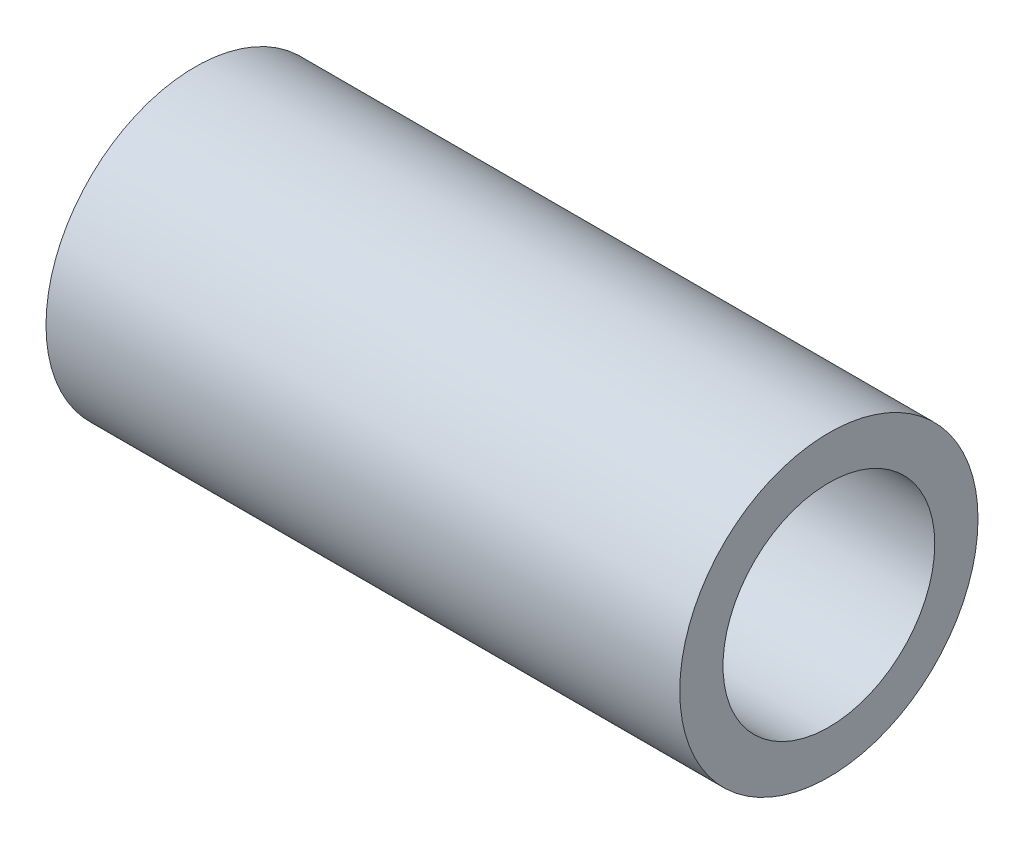
from build123d import *

# Parameters (mm, degrees)
SKETCH2_R          = 12.7
SKETCH2_R_2        = 11.2141
EXTRUDE1_DEPTH     = 28.575
SKETCH3_R          = 12.7
SKETCH3_R_2        = 9.017
EXTRUDE2_DEPTH     = 25.4
SKETCH4_R          = 11.2141
SKETCH4_R_2        = 9.017
CUT_EXTRUDE3_DEPTH = 3.175


with BuildPart() as part:
    # Sketch2 → Extrude1 (new body)
    with BuildSketch(Plane(origin=(0, 0, 0), x_dir=(0, 0, -1), z_dir=(1, 0, 0))):
        Circle(SKETCH2_R)
        Circle(SKETCH2_R_2, mode=Mode.SUBTRACT)
    extrude(amount=EXTRUDE1_DEPTH)

    # Sketch3 → Extrude2 (add)
    with BuildSketch(Plane(origin=(28.575, 0, 0), x_dir=(0, 0, -1), z_dir=(1, 0, 0))):
        Circle(SKETCH3_R)
        Circle(SKETCH3_R_2, mode=Mode.SUBTRACT)
    extrude(amount=EXTRUDE2_DEPTH)

    # Sketch4 → Cut-Extrude3 (cut)
    with BuildSketch(Plane.ZY.offset(-28.575)):
        with Locations(Location((0, 0, 0), (0, 0, 180))):  # turned: the seam where the file's is
            Circle(SKETCH4_R)
        with Locations(Location((0, 0, 0), (0, 0, 180))):  # turned: the seam where the file's is
            Circle(SKETCH4_R_2, mode=Mode.SUBTRACT)
    extrude(amount=-CUT_EXTRUDE3_DEPTH, mode=Mode.SUBTRACT)


solid = part.part
